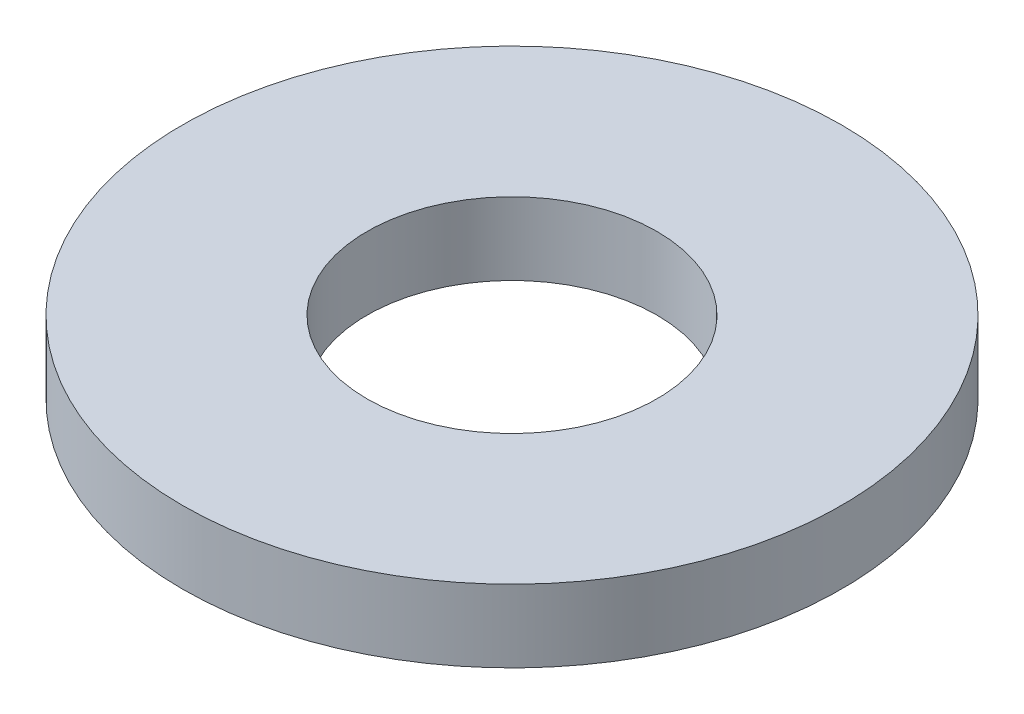
from build123d import *

# Parameters (mm, degrees)
SKETCH_1_R      = 2.5
SKETCH_1_R_2    = 1.1
EXTRUDE_1_DEPTH = 0.55


with BuildPart() as part:
    # 草图1 → 凸台-拉伸1 (new body)
    with BuildSketch(Plane(origin=(0, 0, 0), x_dir=(1, 0, 0), z_dir=(0, 1, 0))):
        Circle(SKETCH_1_R)
        Circle(SKETCH_1_R_2, mode=Mode.SUBTRACT)
    extrude(amount=EXTRUDE_1_DEPTH)


solid = part.part
